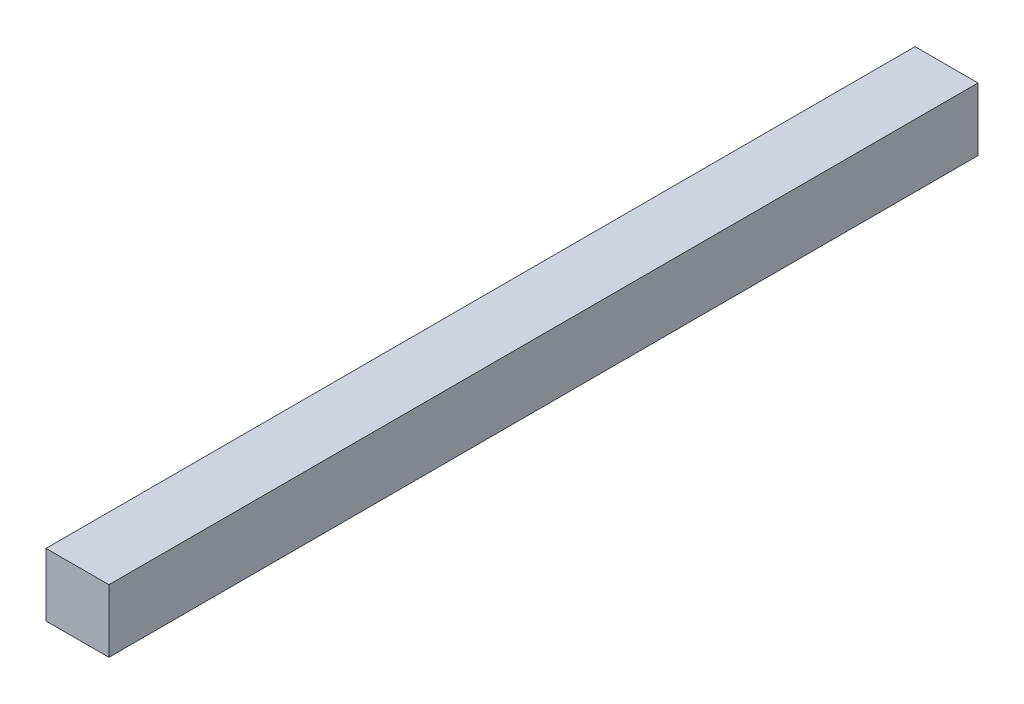
from build123d import *

# Parameters (mm, degrees)
SKETCH1_W           = 42
SKETCH1_H           = 42
SKETCH1_W_2         = 40
SKETCH1_H_2         = 40
BOSS_EXTRUDE1_DEPTH = 580


with BuildPart() as part:
    # Sketch1 → Boss-Extrude1 (new body)
    with BuildSketch(Plane.XY):
        Rectangle(SKETCH1_W, SKETCH1_H)
        Rectangle(SKETCH1_W_2, SKETCH1_H_2, mode=Mode.SUBTRACT)
        Rectangle(SKETCH1_W_2, SKETCH1_H_2)
    extrude(amount=BOSS_EXTRUDE1_DEPTH)


solid = part.part
